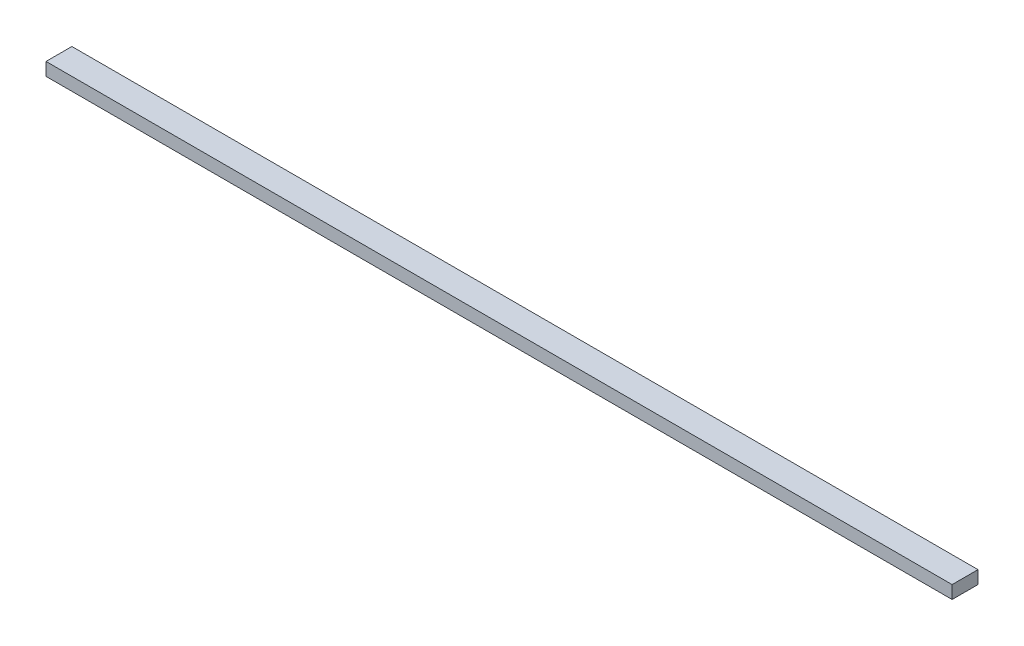
from build123d import *

# Parameters (mm, degrees)
ESQUISSE1_W      = 700
ESQUISSE1_H      = 20
EXTRUSION1_DEPTH = 10


with BuildPart() as part:
    # Esquisse1 → Extrusion1 (new body)
    with BuildSketch(Plane(origin=(0, 0, 0), x_dir=(1, 0, 0), z_dir=(0, 1, 0))):
        with Locations((350, 10)):
            Rectangle(ESQUISSE1_W, ESQUISSE1_H)
    extrude(amount=EXTRUSION1_DEPTH)


solid = part.part
